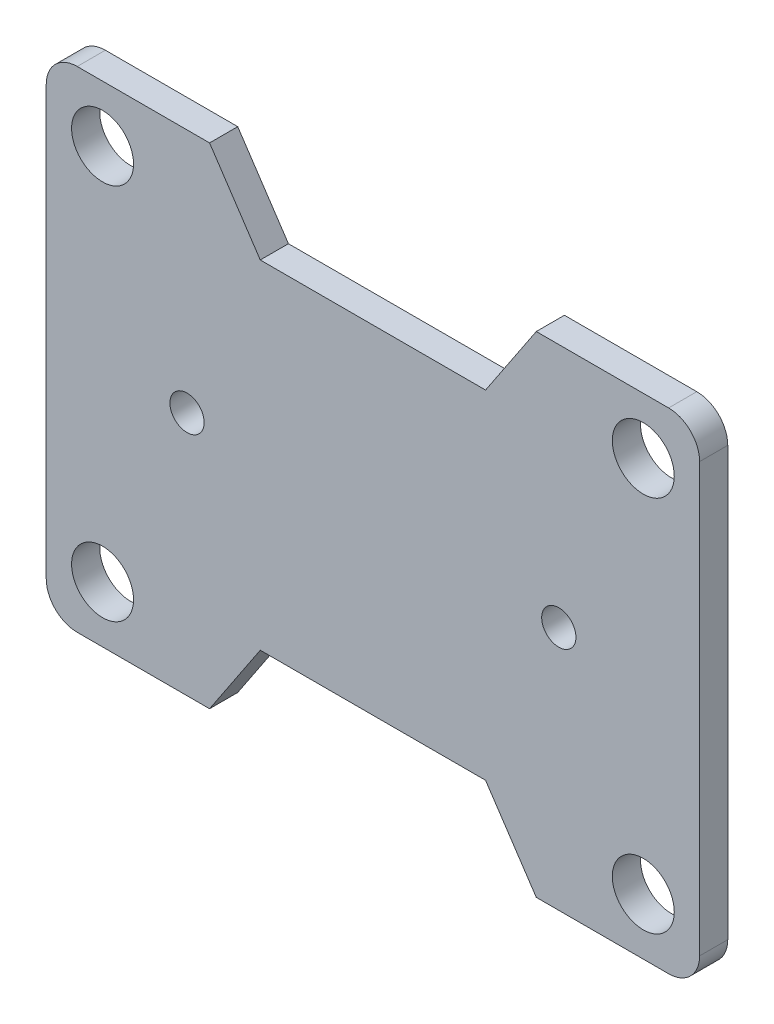
from build123d import *

# Parameters (mm, degrees)
SKETCH1_R           = 2.75
SKETCH1_R_2         = 1.52
BOSS_EXTRUDE1_DEPTH = 2.5
FILLET1_R           = 2.75


with BuildPart() as part:
    # Sketch1 → Boss-Extrude1 (new body)
    with BuildSketch(Plane.XY):
        Polygon((14, 1.75), (34, 1.75), (38.5, -5), (53, -5), (53, 38.5), (38.5, 38.5), (34, 31.75), (14, 31.75), (9.5, 38.5), (-5, 38.5), (-5, -5), (9.5, -5), align=None)
        with Locations((0, 33.5)):
            Circle(SKETCH1_R, mode=Mode.SUBTRACT)
        Circle(SKETCH1_R, mode=Mode.SUBTRACT)
        with Locations((48, 0)):
            Circle(SKETCH1_R, mode=Mode.SUBTRACT)
        with Locations((40.5, 16.75)):
            Circle(SKETCH1_R_2, mode=Mode.SUBTRACT)
        with Locations((7.5, 16.75)):
            Circle(SKETCH1_R_2, mode=Mode.SUBTRACT)
        with Locations((48, 33.5)):
            Circle(SKETCH1_R, mode=Mode.SUBTRACT)
    extrude(amount=BOSS_EXTRUDE1_DEPTH)

    # Fillet1
    fillet1_edges = [part.edges().sort_by_distance(p)[0] for p in [
        (53, -5, 1.25),
        (-5, -5, 1.25),
        (-5, 38.5, 1.25),
        (53, 38.5, 1.25),
    ]]
    fillet(fillet1_edges, radius=FILLET1_R)


solid = part.part
